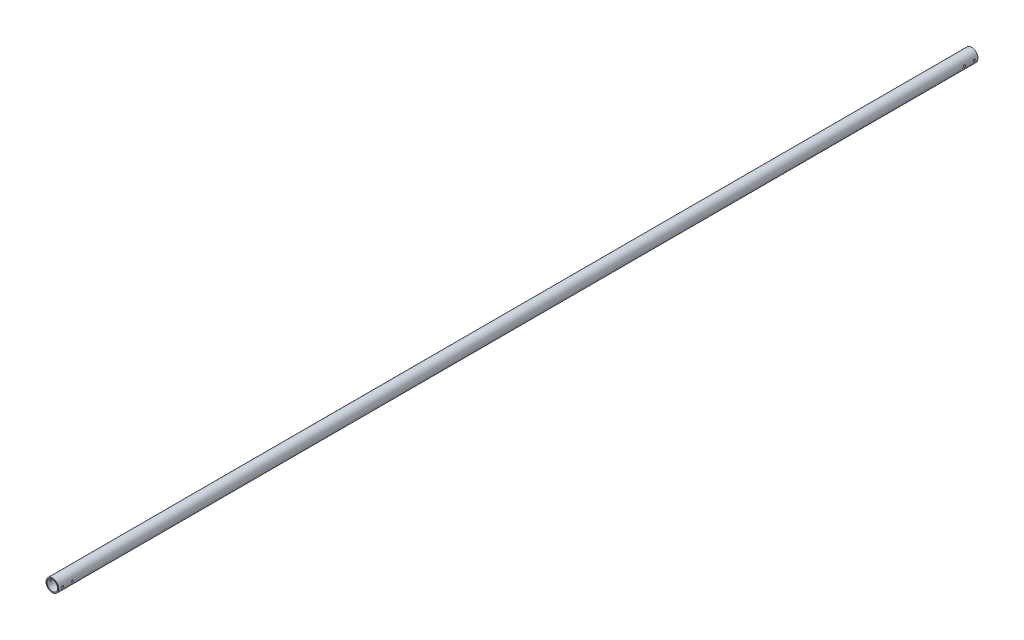
from build123d import *

# Parameters (mm, degrees)
SKETCH1_R               = 21.082
SKETCH1_R_2             = 17.526
BOSS_EXTRUDE1_DEPTH     = 1517.65
F_1_4_CLEARANCE_HOLE1_D = 6.7564


with BuildPart() as part:
    # Sketch1 → Boss-Extrude1 (new body, symmetric)
    with BuildSketch(Plane.XY):
        Circle(SKETCH1_R)
        Circle(SKETCH1_R_2, mode=Mode.SUBTRACT)
    extrude(amount=BOSS_EXTRUDE1_DEPTH, both=True)

    # 1/4 Clearance Hole1 (through all)
    with Locations(Plane(origin=(21.082, 0, 0), x_dir=(0, 0, -1), z_dir=(1, 0, 0))):
        with Locations((-1504.95, 0), (-1473.2, 0), (1504.95, 0), (1473.2, 0)):
            Hole(F_1_4_CLEARANCE_HOLE1_D / 2)


solid = part.part
